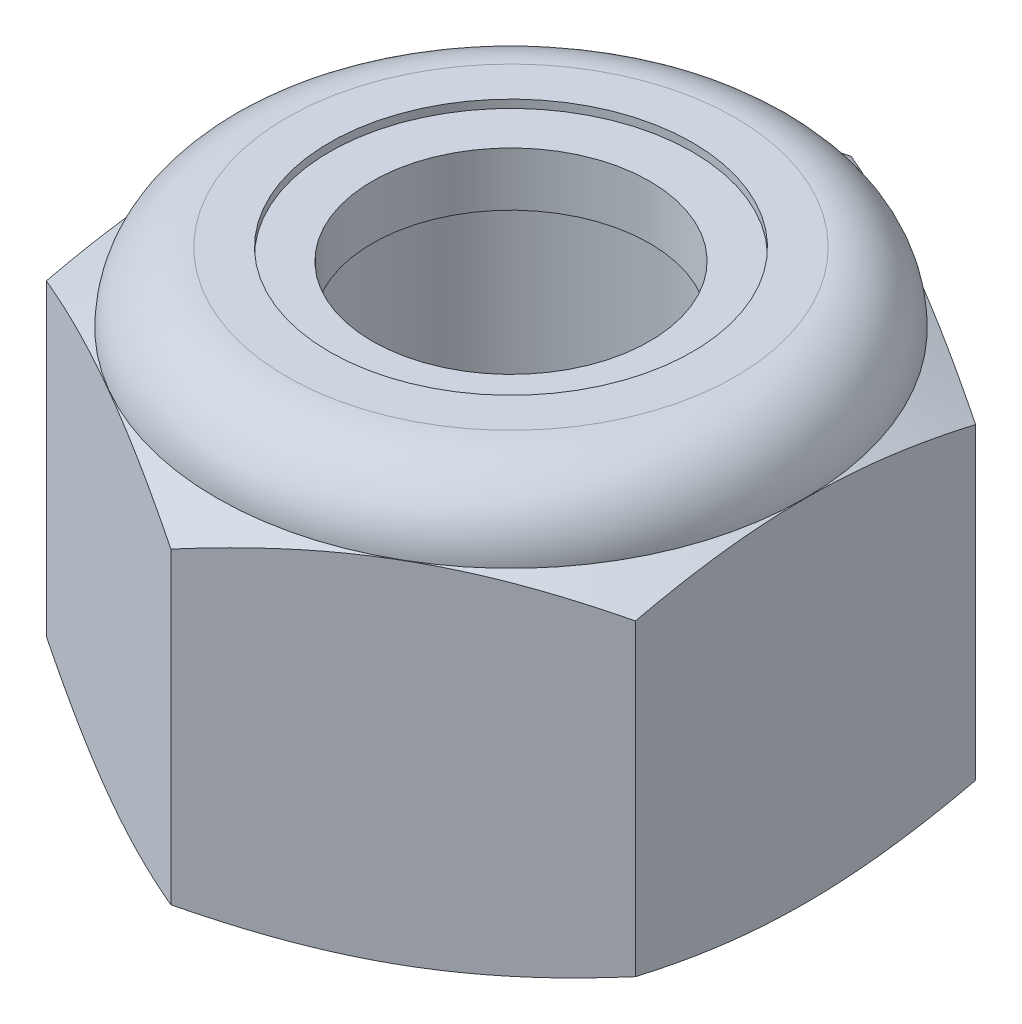
from build123d import *

# Parameters (mm, degrees)
BOSS_EXTRUDE1_DEPTH = 7.9375
SKETCH2_R           = 3.175
CUT_EXTRUDE1_DEPTH  = 8.9375


with BuildPart() as part:
    # Sketch1 → Boss-Extrude1 (new body)
    with BuildSketch(Plane(origin=(0, 0, 0), x_dir=(1, 0, 0), z_dir=(0, 1, 0))):
        Polygon((0, 6.415804866), (-5.55625, 3.207902433), (-5.55625, -3.207902433), (0, -6.415804866), (5.55625, -3.207902433), (5.55625, 3.207902433), align=None)
    extrude(amount=BOSS_EXTRUDE1_DEPTH)

    # Sketch2 → Cut-Extrude1 (cut, through all)
    with BuildSketch(Plane(origin=(0, 7.9375, 0), x_dir=(1, 0, 0), z_dir=(0, 1, 0))):
        Circle(SKETCH2_R)
    extrude(amount=-CUT_EXTRUDE1_DEPTH, mode=Mode.SUBTRACT)

    # Sketch4 → Cut-Revolve1 (revolve, cut)
    with BuildSketch(Plane(origin=(0, 0, 0), x_dir=(0, 0, -1), z_dir=(1, 0, 0))):
        with BuildLine():
            Line((0, 0), (5.552204866, 0))
            Line((5.552204866, 0), (6.415804866, 0.402703294))
            Line((6.415804866, 0.402703294), (6.415804866, 6.213996706))
            Line((6.415804866, 6.213996706), (5.552204866, 6.6167))
            ThreePointArc((5.552204866, 6.6167), (5.165351503, 7.550646637), (4.231404866, 7.9375))
            Line((4.231404866, 7.9375), (4.231404866, 9.2075))
            Line((4.231404866, 9.2075), (7.685804866, 9.2075))
            Line((7.685804866, 9.2075), (7.685804866, -1.27))
            Line((7.685804866, -1.27), (0, -1.27))
            Line((0, -1.27), (0, 0))
        make_face()
    revolve(axis=Axis((0, 0, 0), (0, 1, 0)), mode=Mode.SUBTRACT)

    # Sketch5 → Cut-Revolve2 (revolve, cut)
    with BuildSketch(Plane(origin=(0, 0, 0), x_dir=(0, 0, -1), z_dir=(1, 0, 0))):
        with BuildLine():
            Line((5.399804866, 6.6167), (0, 6.6167))
            Line((0, 6.6167), (0, 9.1567))
            Line((0, 9.1567), (3.421620792, 9.1567))
            Line((3.421620792, 9.1567), (3.421620792, 7.7851))
            Line((3.421620792, 7.7851), (4.231404866, 7.7851))
            ThreePointArc((4.231404866, 7.7851), (5.05758843, 7.442883563), (5.399804866, 6.6167))
        make_face()
    revolve(axis=Axis((0, 6.6167, 0), (0, 1, 0)), mode=Mode.SUBTRACT)


with BuildPart() as body_2:
    # Sketch6 → Revolve1 (revolve)
    with BuildSketch(Plane(origin=(0, 0, 0), x_dir=(0, 0, -1), z_dir=(1, 0, 0))):
        with BuildLine():
            Line((2.6162, 6.6929), (2.6162, 7.7089))
            Line((2.6162, 7.7089), (4.231404866, 7.7089))
            ThreePointArc((4.231404866, 7.7089), (4.976279084, 7.415488608), (5.320943484, 6.6929))
            Line((5.320943484, 6.6929), (2.6162, 6.6929))
        make_face()
    revolve(axis=Axis((0, 0, 0), (0, 1, 0)))


solid = Compound([part.part, body_2.part])
